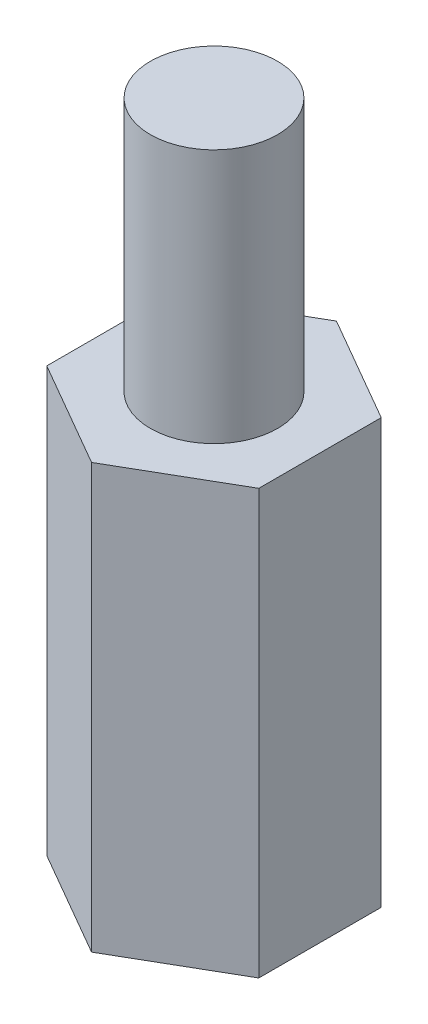
from build123d import *

# Parameters (mm, degrees)
BOSS_EXTRUDE1_DEPTH = 16
SKETCH2_R           = 1.5025
CUT_EXTRUDE1_DEPTH  = 6.005
SKETCH3_R           = 1.5
CUT_EXTRUDE2_DEPTH  = 6


with BuildPart() as part:
    # Sketch1 → Boss-Extrude1 (new body)
    with BuildSketch(Plane(origin=(0, 0, 0), x_dir=(1, 0, 0), z_dir=(0, 1, 0))):
        Polygon((2.5, 1.443375673), (0, 2.886751346), (-2.5, 1.443375673), (-2.5, -1.443375673), (0, -2.886751346), (2.5, -1.443375673), align=None)
    extrude(amount=BOSS_EXTRUDE1_DEPTH)

    # Sketch2 → Cut-Extrude1 (cut)
    with BuildSketch(Plane(origin=(0, 0, 0), x_dir=(1, 0, 0), z_dir=(0, 1, 0))):
        Circle(SKETCH2_R)
    extrude(amount=CUT_EXTRUDE1_DEPTH, mode=Mode.SUBTRACT)

    # Sketch3 → Cut-Extrude2 (cut)
    with BuildSketch(Plane(origin=(0, 16, 0), x_dir=(1, 0, 0), z_dir=(0, 1, 0))):
        Polygon((0, 2.886751346), (-2.5, 1.443375673), (-2.5, -1.443375673), (0, -2.886751346), (2.5, -1.443375673), (2.5, 1.443375673), align=None)
        Circle(SKETCH3_R, mode=Mode.SUBTRACT)
    extrude(amount=-CUT_EXTRUDE2_DEPTH, mode=Mode.SUBTRACT)


solid = part.part
